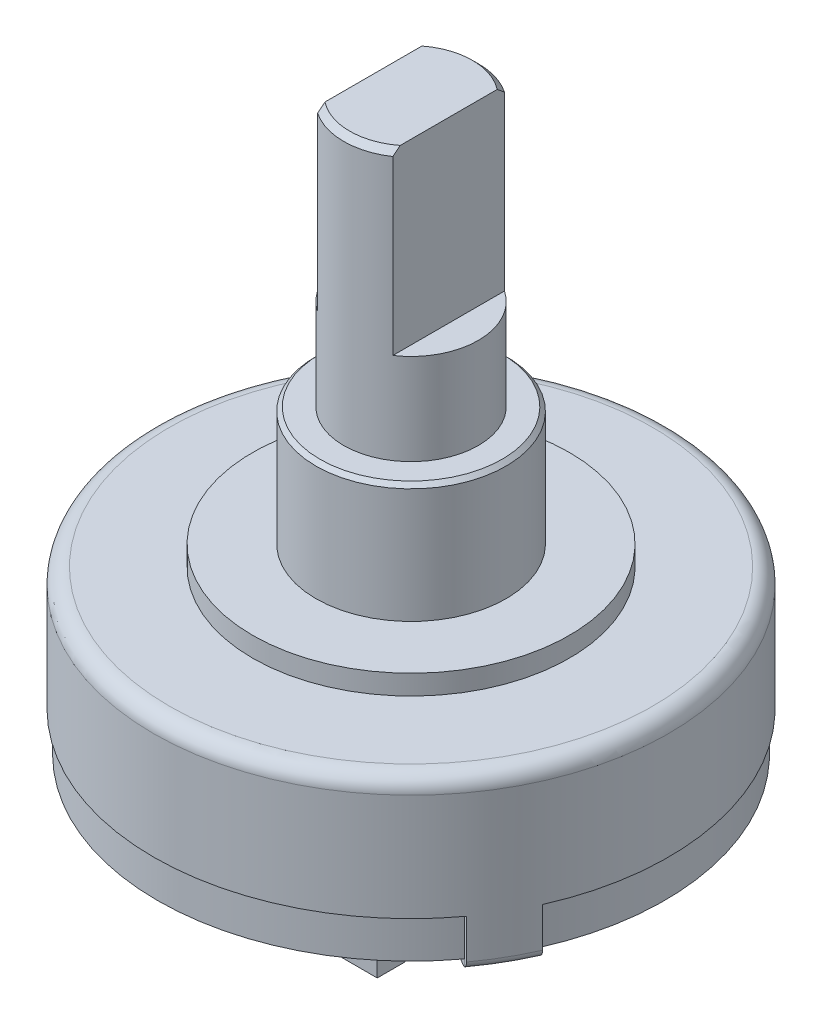
from build123d import *
from build123d.topology import SkipClean

# Parameters (mm, degrees)
SKETCH1_R            = 6.5
BOSS_EXTRUDE1_DEPTH  = 3.1
SKETCH2_R            = 4
BOSS_EXTRUDE2_DEPTH  = 0.5
SKETCH3_R            = 2.4
BOSS_EXTRUDE3_DEPTH  = 3
SKETCH4_R            = 1.7
BOSS_EXTRUDE4_DEPTH  = 6.8
CHAMFER1_SIZE        = 0.15
CUT_EXTRUDE1_DEPTH   = 4.5
SKETCH6_R            = 6.4
BOSS_EXTRUDE5_DEPTH  = 1
FILLET1_R            = 0.4
CHAMFER2_SIZE        = 0.1
BOSS_EXTRUDE6_DEPTH  = 1.2
SKETCH8_W            = 1.400599112
SKETCH8_H            = 0.2
BOSS_EXTRUDE7_DEPTH  = 1.2
SKETCH9_W            = 1.400599112
SKETCH9_H            = 0.2
BOSS_EXTRUDE8_DEPTH  = 1.2
SKETCH10_W           = 1.370501576
SKETCH10_H           = 0.2
BOSS_EXTRUDE9_DEPTH  = 1.2
FILLET2_R            = 0.5
FILLET3_R            = 0.2
SKETCH11_W           = 1.09784978
SKETCH11_H           = 0.766423431
SKETCH11_W_2         = 1.035707339
SKETCH11_H_2         = 0.70428099
SKETCH11_W_3         = 1.242848807
BOSS_EXTRUDE10_DEPTH = 2


with BuildPart() as part:
    # Sketch1 → Boss-Extrude1 (new body)
    with BuildSketch(Plane(origin=(0, 0, 0), x_dir=(1, 0, 0), z_dir=(0, 1, 0))):
        with Locations(Location((0, 0, 0), (0, 0, 90))):
            Circle(SKETCH1_R)
    extrude(amount=BOSS_EXTRUDE1_DEPTH)

    # Sketch2 → Boss-Extrude2 (add)
    with BuildSketch(Plane(origin=(0, 3.1, 0), x_dir=(1, 0, 0), z_dir=(0, 1, 0))):
        with Locations(Location((0, 0, 0), (0, 0, 270))):
            Circle(SKETCH2_R)
    extrude(amount=BOSS_EXTRUDE2_DEPTH)

    # Sketch3 → Boss-Extrude3 (add)
    with BuildSketch(Plane(origin=(0, 3.6, 0), x_dir=(-1, 0, 0), z_dir=(0, 1, 0))):
        with Locations(Location((0, 0, 0), (0, 0, 90))):
            Circle(SKETCH3_R)
    extrude(amount=BOSS_EXTRUDE3_DEPTH)

    # Sketch4 → Boss-Extrude4 (add)
    with BuildSketch(Plane(origin=(0, 6.6, 0), x_dir=(1, 0, 0), z_dir=(0, 1, 0))):
        with Locations(Location((0, 0, 0), (0, 0, 270))):
            Circle(SKETCH4_R)
    extrude(amount=BOSS_EXTRUDE4_DEPTH)

    # Chamfer1
    chamfer1_edges = [part.edges().sort_by_distance(p)[0] for p in [
        (0, 13.4, -1.7),
    ]]
    chamfer(chamfer1_edges, length=CHAMFER1_SIZE)

    # Sketch5 → Cut-Extrude1 (cut)
    with BuildSketch(Plane(origin=(0, 13.4, 0), x_dir=(1, 0, 0), z_dir=(0, 1, 0))):
        Polygon((0.95, 0), (0.95, 1.953547683), (2.291589772, 1.953547683), (2.291589772, -1.88704126), (0.95, -1.88704126), align=None)
        Polygon((-0.95, 0), (-0.95, 2.055691006), (-2.284431096, 2.055691006), (-2.21293077, -1.815540934), (-0.95, -1.815540934), align=None)
    extrude(amount=-CUT_EXTRUDE1_DEPTH, mode=Mode.SUBTRACT)

    # Sketch6 → Boss-Extrude5 (add)
    with BuildSketch(Plane.XZ):
        with Locations(Location((0, 0, 0), (0, 0, 90))):
            Circle(SKETCH6_R)
    extrude(amount=BOSS_EXTRUDE5_DEPTH)

    # Fillet1
    fillet1_edges = [part.edges().sort_by_distance(p)[0] for p in [
        (0, 3.1, 6.5),
    ]]
    fillet(fillet1_edges, radius=FILLET1_R)

    # Chamfer2
    chamfer2_edges = [part.edges().sort_by_distance(p)[0] for p in [
        (0, 6.6, -2.4),
    ]]
    chamfer(chamfer2_edges, length=CHAMFER2_SIZE)

    # Sketch7 → Boss-Extrude6 (add)
    with SkipClean():  # the faces are left unmerged after this step: merging them gives an invalid solid
        with BuildSketch(Plane.XZ):
            with BuildLine():
                Line((5.151524141, 3.79760438), (5.242126256, 3.843190382))
                ThreePointArc((5.242126256, 3.843190382), (5.626855667, 3.253996819), (5.945638893, 2.626666738))
                Line((5.945638893, 2.626666738), (5.854255539, 2.586057247))
                Line((5.854255539, 2.586057247), (5.151524141, 3.79760438))
            make_face()
            with BuildLine():
                Line((-5.242126256, 3.843190382), (-5.151524141, 3.79760438))
                Line((-5.151524141, 3.79760438), (-5.854255539, 2.586057247))
                Line((-5.854255539, 2.586057247), (-5.945638893, 2.626666738))
                ThreePointArc((-5.945638893, 2.626666738), (-5.626855667, 3.253996819), (-5.242126256, 3.843190382))
            make_face()
            with BuildLine():
                Line((-0.7, -6.462197769), (-0.688624102, -6.362845028))
                Line((-0.688624102, -6.362845028), (0.681877282, -6.363571589))
                Line((0.681877282, -6.363571589), (0.7, -6.462197769))
                ThreePointArc((0.7, -6.462197769), (0, -6.5), (-0.7, -6.462197769))
            make_face()
        extrude(amount=BOSS_EXTRUDE6_DEPTH)

    # Sketch8 → Boss-Extrude7 (add)
    with SkipClean():  # the faces are left unmerged after this step: merging them gives an invalid solid
        with BuildSketch(Plane(origin=(5.50288984, 0, 3.191830814), x_dir=(-0.5017362869920535, 0, 0.8650206346182893), z_dir=(-0.8650206346182893, 0, -0.5017362869920535))):
            with Locations((0, -1.1)):
                Rectangle(SKETCH8_W, SKETCH8_H)
        extrude(amount=BOSS_EXTRUDE7_DEPTH)

    # Sketch9 → Boss-Extrude8 (add)
    with SkipClean():  # the faces are left unmerged after this step: merging them gives an invalid solid
        with BuildSketch(Plane(origin=(-5.50288984, 0, 3.191830814), x_dir=(-0.5017362869920535, 0, -0.8650206346182893), z_dir=(0.8650206346182893, 0, -0.5017362869920535))):
            with Locations((0, -1.1)):
                Rectangle(SKETCH9_W, SKETCH9_H)
        extrude(amount=BOSS_EXTRUDE8_DEPTH)

    # Sketch10 → Boss-Extrude9 (add)
    with SkipClean():  # the faces are left unmerged after this step: merging them gives an invalid solid
        with BuildSketch(Plane(origin=(-0.00337341, 0, -6.363208308), x_dir=(0.9999998594742814, 0, -0.0005301428274771333), z_dir=(0.0005301428274771333, 0, 0.9999998594742814))):
            with Locations((0, -1.1)):
                Rectangle(SKETCH10_W, SKETCH10_H)
        extrude(amount=BOSS_EXTRUDE9_DEPTH)

    # Fillet2
    fillet2_edges = [part.edges().sort_by_distance(p)[0] for p in [
        (4.113499379, -1.1, 3.195520836),
        (4.816230777, -1.1, 1.983973703),
        (-4.113499379, -1.1, 3.195520836),
        (-4.816230777, -1.1, 1.983973703),
        (0.682513454, -1.1, -5.163571758),
        (-0.68798793, -1.1, -5.162845196),
    ]]
    fillet(fillet2_edges, radius=FILLET2_R)

    # Fillet3
    fillet3_edges = [part.edges().sort_by_distance(p)[0] for p in [
        (5.626855667, -1.2, 3.253996819),
        (0, -1.2, -6.5),
        (-5.626855667, -1.2, 3.253996819),
    ]]
    fillet(fillet3_edges, radius=FILLET3_R)

    # Sketch11 → Boss-Extrude10 (add)
    with BuildSketch(Plane.XZ.offset(1)):
        with Locations((-0.051193187, 1.87960604)):
            Rectangle(SKETCH11_W, SKETCH11_H)
        with Locations((1.947721978, 2.967098746)):
            Rectangle(SKETCH11_W_2, SKETCH11_H_2)
        with Locations((-2.505819581, 2.967098746)):
            Rectangle(SKETCH11_W_3, SKETCH11_H_2)
    extrude(amount=BOSS_EXTRUDE10_DEPTH)


solid = part.part
